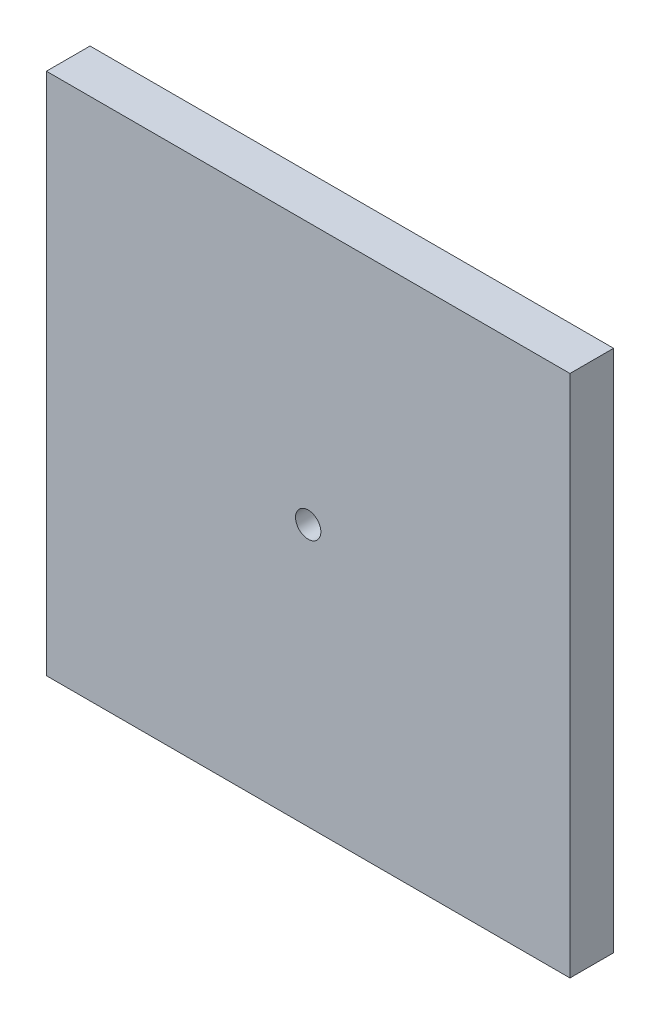
from build123d import *

# Parameters (mm, degrees)
SKETCH1_W           = 76.2
SKETCH1_H           = 76.2
SKETCH1_R           = 1.8415
BOSS_EXTRUDE1_DEPTH = 6.35


with BuildPart() as part:
    # Sketch1 → Boss-Extrude1 (new body)
    with BuildSketch(Plane.XY):
        with Locations((38.1, 38.1)):
            Rectangle(SKETCH1_W, SKETCH1_H)
        with Locations((38.1, 38.1)):
            Circle(SKETCH1_R, mode=Mode.SUBTRACT)
    extrude(amount=BOSS_EXTRUDE1_DEPTH)


solid = part.part
